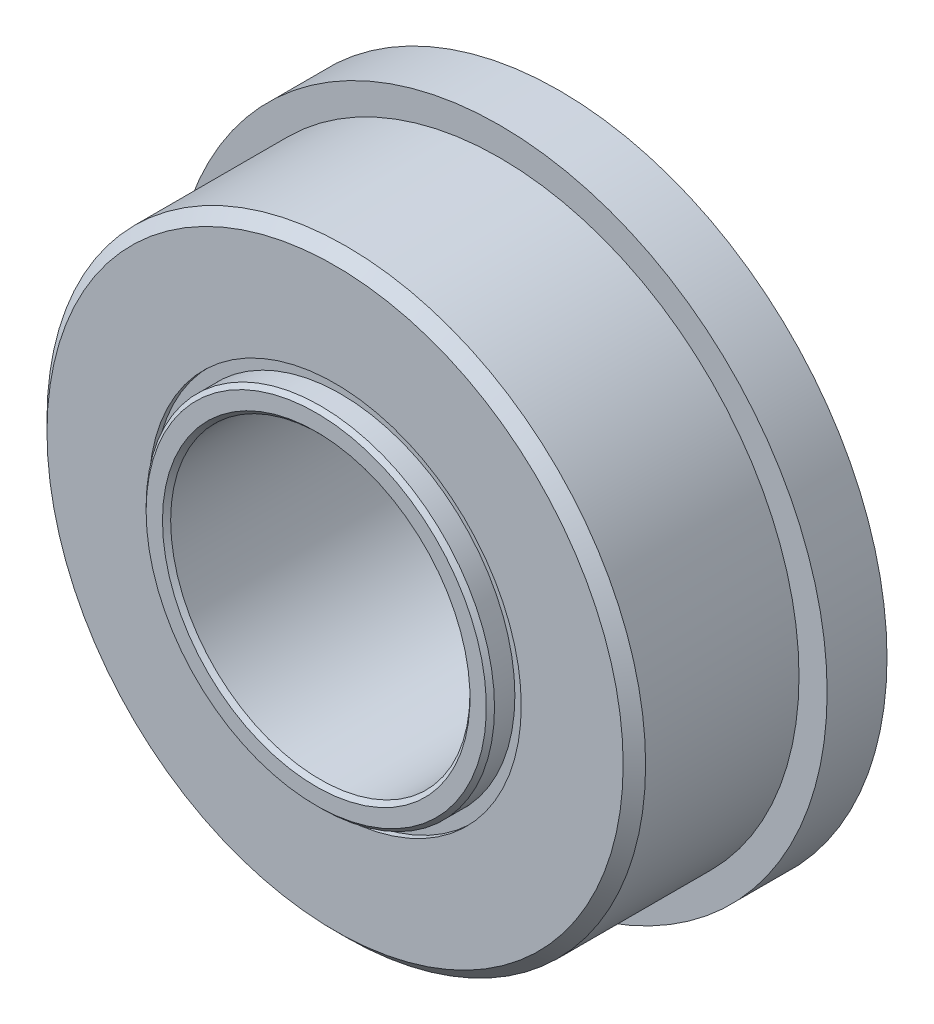
from build123d import *

# Parameters (mm, degrees)
CHAMFER1_SIZE     = 0.086783333
CIRPATTERN1_COUNT = 12
SKETCH5_W         = 1.4684375
SKETCH5_H         = 0.254
SKETCH6_W         = 1.27
SKETCH6_H         = 2.9972


with BuildPart() as part:
    # Sketch1 → Revolve1 (revolve)
    with BuildSketch(Plane(origin=(0, 0, 0), x_dir=(0, 0, -1), z_dir=(1, 0, 0))):
        with BuildLine():
            Line((2.143125, 6.35), (-2.143125, 6.35))
            Line((-2.143125, 6.35), (-2.38125, 6.111875))
            Line((-2.38125, 6.111875), (-2.38125, 3.9497))
            Line((-2.38125, 3.9497), (-0.74295, 3.9497))
            ThreePointArc((-0.74295, 3.9497), (0, 5.02285), (0.74295, 3.9497))
            Line((0.74295, 3.9497), (2.38125, 3.9497))
            Line((2.38125, 3.9497), (2.38125, 6.111875))
            Line((2.38125, 6.111875), (2.143125, 6.35))
        make_face()
        with BuildLine():
            Line((2.7813, 3.6957), (0.587812472, 3.6957))
            ThreePointArc((0.587812472, 3.6957), (0, 3.43535), (-0.587812472, 3.6957))
            Line((-0.587812472, 3.6957), (-2.7813, 3.6957))
            Line((-2.7813, 3.6957), (-2.7813, 3.175))
            Line((-2.7813, 3.175), (2.7813, 3.175))
            Line((2.7813, 3.175), (2.7813, 3.6957))
        make_face()
    revolve(axis=Axis((0, 0, 2.38125), (0, 0, -1)))

    # Chamfer1
    chamfer1_edges = [part.edges().sort_by_distance(p)[0] for p in [
        (0, -3.6957, -2.7813),
        (0, -3.175, -2.7813),
        (0, -3.175, 2.7813),
        (0, -3.6957, 2.7813),
    ]]
    chamfer(chamfer1_edges, length=CHAMFER1_SIZE)

    # Sketch6 → Revolve6 (revolve)
    with BuildSketch(Plane(origin=(0, 0, 0), x_dir=(0, 0, -1), z_dir=(1, 0, 0))):
        with Locations((1.74625, 5.4483)):
            Rectangle(SKETCH6_W, SKETCH6_H)
    revolve(axis=Axis((0, 0, -2.38125), (0, 0, 1)))


with BuildPart() as body_2:
    # Sketch4 → Revolve4 (revolve)
    with BuildSketch(Plane(origin=(0, 0, 0), x_dir=(0, 0, -1), z_dir=(1, 0, 0))):
        with BuildLine():
            Line((-0.79375, 4.2291), (0.79375, 4.2291))
            ThreePointArc((0.79375, 4.2291), (0, 5.02285), (-0.79375, 4.2291))
        make_face()
    revolve(axis=Axis((0, 4.2291, 0.79375), (0, 0, -1)))


with BuildPart() as cirpattern1_1:
    # CirPattern1: pattern copy
    add(body_2.part.rotate(Axis((0, 0, 0), (0, 0, 1)), 1 * 360 / CIRPATTERN1_COUNT))


with BuildPart() as cirpattern1_2:
    # CirPattern1: pattern copy
    add(body_2.part.rotate(Axis((0, 0, 0), (0, 0, 1)), 2 * 360 / CIRPATTERN1_COUNT))


with BuildPart() as cirpattern1_3:
    # CirPattern1: pattern copy
    add(body_2.part.rotate(Axis((0, 0, 0), (0, 0, 1)), 3 * 360 / CIRPATTERN1_COUNT))


with BuildPart() as cirpattern1_4:
    # CirPattern1: pattern copy
    add(body_2.part.rotate(Axis((0, 0, 0), (0, 0, 1)), 4 * 360 / CIRPATTERN1_COUNT))


with BuildPart() as cirpattern1_5:
    # CirPattern1: pattern copy
    add(body_2.part.rotate(Axis((0, 0, 0), (0, 0, 1)), 5 * 360 / CIRPATTERN1_COUNT))


with BuildPart() as cirpattern1_6:
    # CirPattern1: pattern copy
    add(body_2.part.rotate(Axis((0, 0, 0), (0, 0, 1)), 6 * 360 / CIRPATTERN1_COUNT))


with BuildPart() as cirpattern1_7:
    # CirPattern1: pattern copy
    add(body_2.part.rotate(Axis((0, 0, 0), (0, 0, 1)), 7 * 360 / CIRPATTERN1_COUNT))


with BuildPart() as cirpattern1_8:
    # CirPattern1: pattern copy
    add(body_2.part.rotate(Axis((0, 0, 0), (0, 0, 1)), 8 * 360 / CIRPATTERN1_COUNT))


with BuildPart() as cirpattern1_9:
    # CirPattern1: pattern copy
    add(body_2.part.rotate(Axis((0, 0, 0), (0, 0, 1)), 9 * 360 / CIRPATTERN1_COUNT))


with BuildPart() as cirpattern1_10:
    # CirPattern1: pattern copy
    add(body_2.part.rotate(Axis((0, 0, 0), (0, 0, 1)), 10 * 360 / CIRPATTERN1_COUNT))


with BuildPart() as cirpattern1_11:
    # CirPattern1: pattern copy
    add(body_2.part.rotate(Axis((0, 0, 0), (0, 0, 1)), 11 * 360 / CIRPATTERN1_COUNT))


with BuildPart() as body_14:
    # Sketch5 → Revolve5 (revolve)
    with BuildSketch(Plane(origin=(0, 0, 0), x_dir=(0, 0, -1), z_dir=(1, 0, 0))):
        with Locations((-1.52796875, 3.8227)):
            Rectangle(SKETCH5_W, SKETCH5_H)
        with Locations((1.52796875, 3.8227)):
            Rectangle(SKETCH5_W, SKETCH5_H)
    revolve(axis=Axis((0, 0, 2.38125), (0, 0, -1)))


solid = Compound([part.part, body_2.part, cirpattern1_1.part, cirpattern1_2.part, cirpattern1_3.part, cirpattern1_4.part, cirpattern1_5.part, cirpattern1_6.part, cirpattern1_7.part, cirpattern1_8.part, cirpattern1_9.part, cirpattern1_10.part, cirpattern1_11.part, body_14.part])
